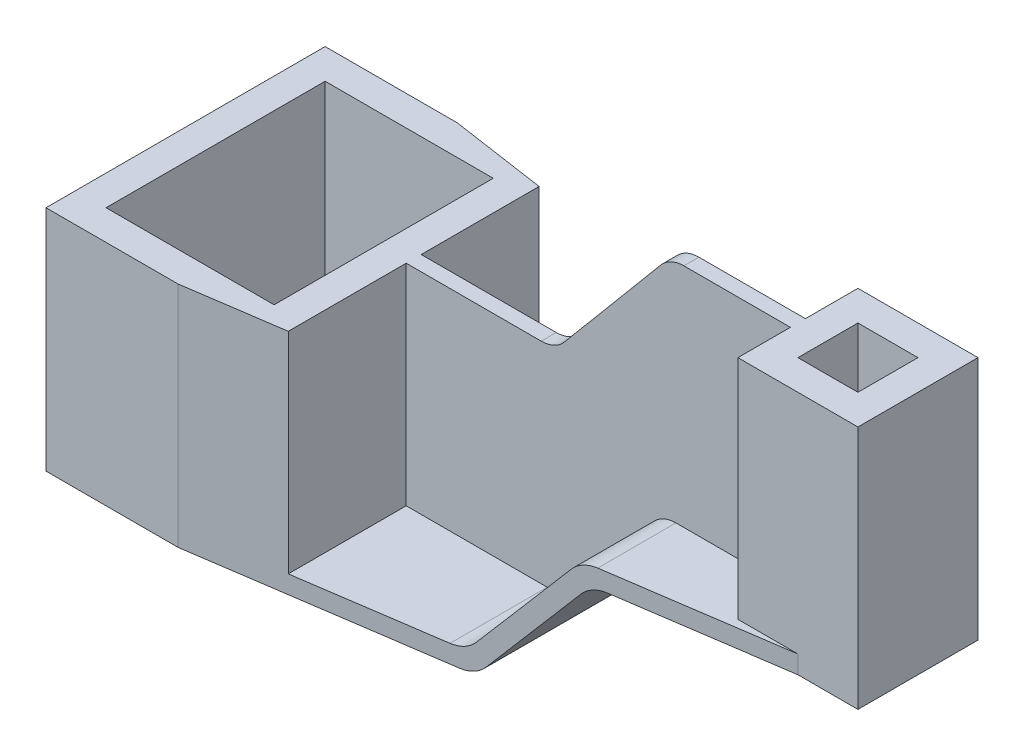
from build123d import *

# Parameters (mm, degrees)
SKIZZE1_W                       = 76
SKIZZE1_H                       = 93
AUFSATZ_LINEAR_AUSTRAGEN1_DEPTH = 76
AUFSATZ_LINEAR_AUSTRAGEN2_DEPTH = 46.5
SKIZZE3_W                       = 40
SKIZZE3_H                       = 40
AUFSATZ_LINEAR_AUSTRAGEN3_DEPTH = 81.5
AUFSATZ_LINEAR_AUSTRAGEN4_DEPTH = 2.5
SKIZZE5_W                       = 20
SKIZZE5_H                       = 20
SCHNITT_LINEAR_AUSTRAGEN1_DEPTH = 122.5
SKIZZE6_W                       = 56
SKIZZE6_H                       = 73
SCHNITT_LINEAR_AUSTRAGEN2_DEPTH = 77
SCHNITT_LINEAR_AUSTRAGEN3_DEPTH = 122.5
VERRUNDUNG1_R                   = 10


with BuildPart() as part:
    # Skizze1 → Aufsatz-Linear austragen1 (new body)
    with BuildSketch(Plane(origin=(0, 0, 0), x_dir=(1, 0, 0), z_dir=(0, 1, 0))):
        Rectangle(SKIZZE1_W, SKIZZE1_H)
    extrude(amount=AUFSATZ_LINEAR_AUSTRAGEN1_DEPTH)

    # Skizze2 → Aufsatz-Linear austragen2 (add, symmetric)
    with BuildSketch(Plane.XY):
        Polygon((38, 0), (92.436014753, 0), (126, 40), (186, 40), (186, 46), (123.202154051, 46), (89.638168804, 6), (38, 6), align=None)
    extrude(amount=AUFSATZ_LINEAR_AUSTRAGEN2_DEPTH, both=True)

    # Skizze3 → Aufsatz-Linear austragen3 (add)
    with BuildSketch(Plane.XZ.offset(-40)):
        with Locations((186, 0)):
            Rectangle(SKIZZE3_W, SKIZZE3_H)
    extrude(amount=-AUFSATZ_LINEAR_AUSTRAGEN3_DEPTH)

    # Skizze4 → Aufsatz-Linear austragen4 (add, symmetric)
    with BuildSketch(Plane.XY):
        Polygon((38, 76), (87.673704032, 76), (125.852737251, 121.5), (166, 121.5), (166, 46), (123.202154051, 46), (89.638168804, 6), (38, 6), align=None)
    extrude(amount=AUFSATZ_LINEAR_AUSTRAGEN4_DEPTH, both=True)

    # Skizze5 → Schnitt-Linear austragen1 (cut, through all)
    with BuildSketch(Plane(origin=(0, 121.5, 0), x_dir=(1, 0, 0), z_dir=(0, 1, 0))):
        with Locations((186, 0)):
            Rectangle(SKIZZE5_W, SKIZZE5_H)
    extrude(amount=-SCHNITT_LINEAR_AUSTRAGEN1_DEPTH, mode=Mode.SUBTRACT)

    # Skizze6 → Schnitt-Linear austragen2 (cut, through all)
    with BuildSketch(Plane(origin=(0, 76, 0), x_dir=(1, 0, 0), z_dir=(0, 1, 0))):
        Rectangle(SKIZZE6_W, SKIZZE6_H)
    extrude(amount=-SCHNITT_LINEAR_AUSTRAGEN2_DEPTH, mode=Mode.SUBTRACT)

    # Skizze7 → Schnitt-Linear austragen3 (cut, through all)
    with BuildSketch(Plane(origin=(0, 121.5, 0), x_dir=(1, 0, 0), z_dir=(0, 1, 0))):
        Polygon((6, 46.5), (186, 20), (186, 46.5), align=None)
        Polygon((6, -46.5), (186, -20), (186, -46.5), align=None)
    extrude(amount=-SCHNITT_LINEAR_AUSTRAGEN3_DEPTH, mode=Mode.SUBTRACT)

    # Verrundung1
    verrundung1_edges = [part.edges().sort_by_distance(p)[0] for p in [
        (126, 40, 0),
        (92.436014753, 0, 0),
        (89.638168804, 6, 18.343301463),
        (123.202154051, 46, 15.872619216),
        (89.638168804, 6, -18.343301463),
        (123.202154051, 46, -15.872619216),
        (125.852737251, 121.5, 0),
        (87.673704032, 76, 0),
    ]]
    fillet(verrundung1_edges, radius=VERRUNDUNG1_R)


solid = part.part
